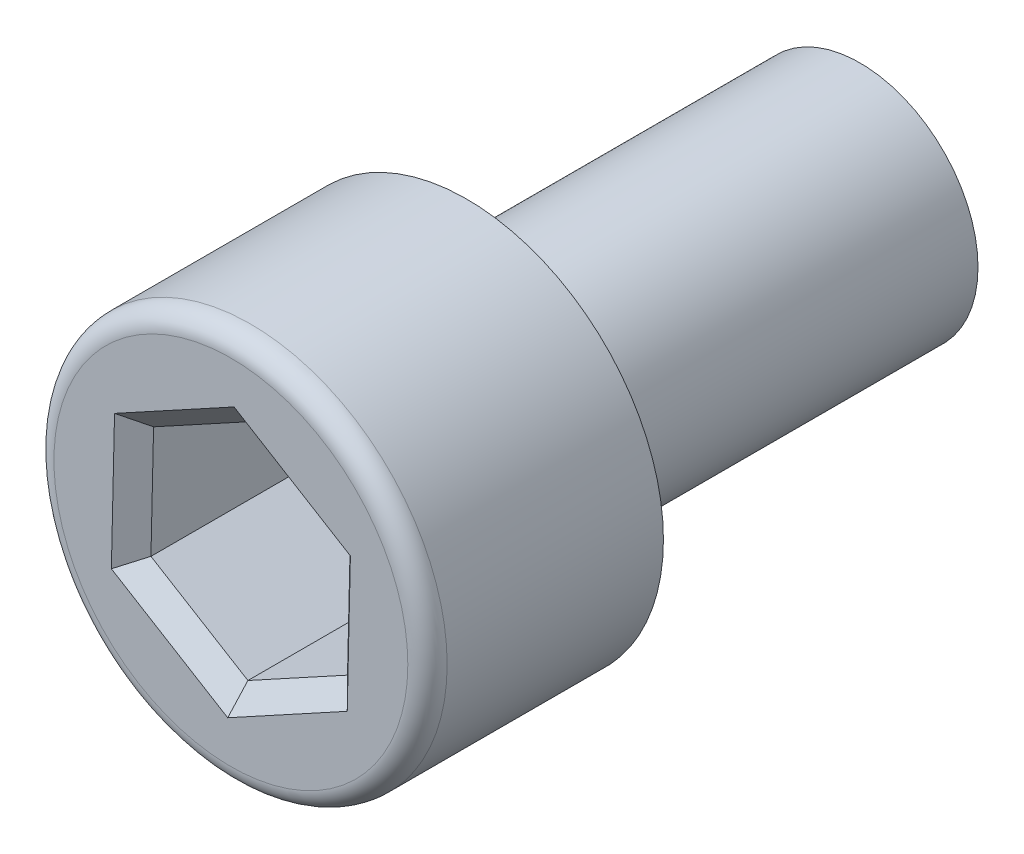
from build123d import *

# Parameters (mm, degrees)
SKETCH2_R          = 3
EXTRUDE1_DEPTH     = 10
SKETCH3_R          = 5
EXTRUDE2_DEPTH     = 6
CUT_EXTRUDE1_DEPTH = 6
FILLET1_R          = 0.5
CHAMFER1_SIZE      = 0.5


with BuildPart() as part:
    # Sketch2 → Extrude1 (new body)
    with BuildSketch(Plane.XY):
        Circle(SKETCH2_R)
    extrude(amount=-EXTRUDE1_DEPTH)

    # Sketch3 → Extrude2 (add)
    with BuildSketch(Plane.XY):
        Circle(SKETCH3_R)
    extrude(amount=EXTRUDE2_DEPTH)

    # Sketch4 → Cut-Extrude1 (cut)
    with BuildSketch(Plane.XY.offset(6)):
        Polygon((-2.46568884, 1.501236783), (-2.532953611, -1.384730781), (-0.067264771, -2.885967565), (2.46568884, -1.501236783), (2.532953611, 1.384730781), (0.067264771, 2.885967565), align=None)
    extrude(amount=-CUT_EXTRUDE1_DEPTH, mode=Mode.SUBTRACT)

    # Fillet1
    fillet1_edges = [part.edges().sort_by_distance(p)[0] for p in [
        (-5, 0, 6),
    ]]
    fillet(fillet1_edges, radius=FILLET1_R)

    # Chamfer1
    chamfer1_edges = [part.edges().sort_by_distance(p)[0] for p in [
        (-1.199212034, 2.193602174, 6),
        (-2.499321225, 0.058253001, 6),
        (-1.300109191, -2.135349173, 6),
        (1.199212034, -2.193602174, 6),
        (2.499321225, -0.058253001, 6),
        (1.300109191, 2.135349173, 6),
    ]]
    chamfer(chamfer1_edges, length=CHAMFER1_SIZE)


solid = part.part
